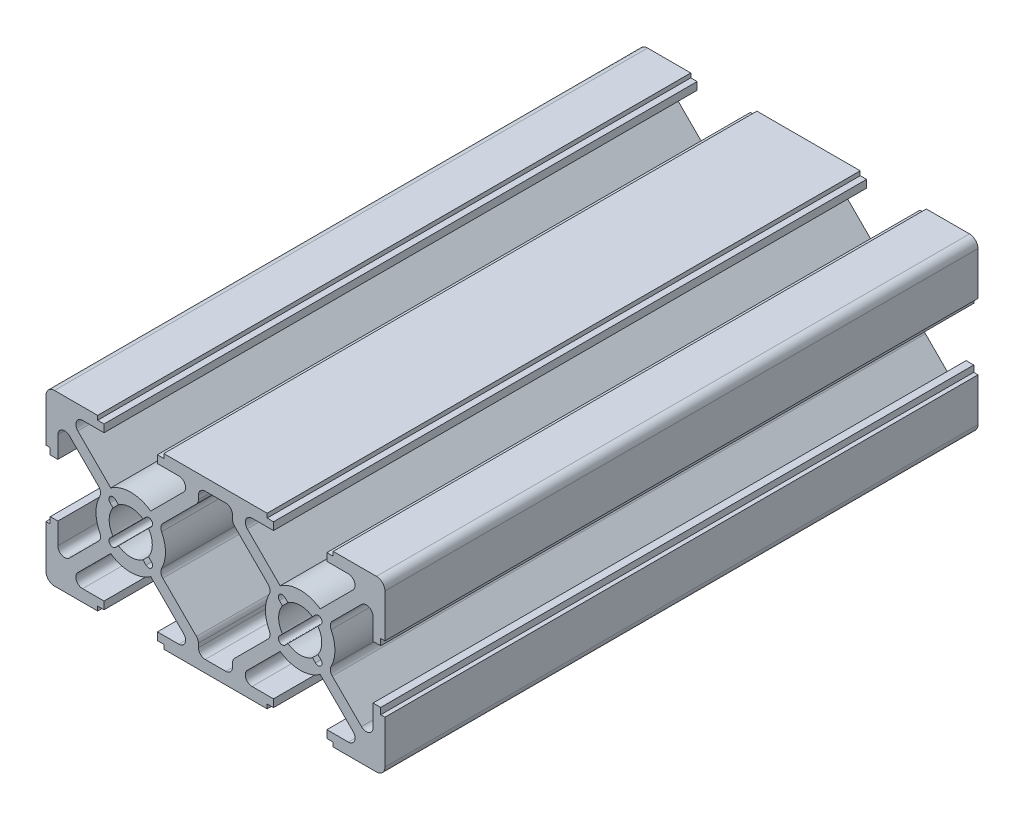
from build123d import *

# Parameters (mm, degrees)
Y_KSEKLIK_EKSTR_ZYON2_DEPTH = 70
RADYUS1_R                   = 0.8


with BuildPart() as part:
    # Çizim3 → Yükseklik-Ekstrüzyon2 (new body)
    with BuildSketch(Plane.XY):
        with BuildLine():
            Line((1, 0), (6.1, 0))
            Line((6.1, 0), (6.1, 0.5))
            Line((6.1, 0.5), (6.85, 0.5))
            Line((6.85, 0.5), (6.85, 1.4))
            Line((6.85, 1.4), (4.321320344, 1.4))
            ThreePointArc((4.321320344, 1.4), (3.582216718, 1.893853254), (3.755634919, 2.765685425))
            Line((3.755634919, 2.765685425), (7.638403375, 6.648453882))
            ThreePointArc((7.638403375, 6.648453882), (10, 5.9), (12.361596625, 6.648453882))
            Line((12.361596625, 6.648453882), (16.244365081, 2.765685425))
            ThreePointArc((16.244365081, 2.765685425), (16.417783282, 1.893853254), (15.678679656, 1.4))
            Line((15.678679656, 1.4), (13.15, 1.4))
            Line((13.15, 1.4), (13.15, 0.5))
            Line((13.15, 0.5), (13.9, 0.5))
            Line((13.9, 0.5), (13.9, 0))
            Line((13.9, 0), (26.1, 0))
            Line((26.1, 0), (26.1, 0.5))
            Line((26.1, 0.5), (26.85, 0.5))
            Line((26.85, 0.5), (26.85, 1.4))
            Line((26.85, 1.4), (24.321320344, 1.4))
            ThreePointArc((24.321320344, 1.4), (23.582216718, 1.893853254), (23.755634919, 2.765685425))
            Line((23.755634919, 2.765685425), (27.638403375, 6.648453882))
            ThreePointArc((27.638403375, 6.648453882), (30, 5.9), (32.361596625, 6.648453882))
            Line((32.361596625, 6.648453882), (36.244365081, 2.765685425))
            ThreePointArc((36.244365081, 2.765685425), (36.417783282, 1.893853254), (35.678679656, 1.4))
            Line((35.678679656, 1.4), (33.15, 1.4))
            Line((33.15, 1.4), (33.15, 0.5))
            Line((33.15, 0.5), (33.9, 0.5))
            Line((33.9, 0.5), (33.9, 0))
            Line((33.9, 0), (39, 0))
            ThreePointArc((39, 0), (39.707106781, 0.292893219), (40, 1))
            Line((40, 1), (40, 6.1))
            Line((40, 6.1), (39.5, 6.1))
            Line((39.5, 6.1), (39.5, 6.85))
            Line((39.5, 6.85), (38.6, 6.85))
            Line((38.6, 6.85), (38.6, 4.321320344))
            ThreePointArc((38.6, 4.321320344), (38.106146746, 3.582216718), (37.234314575, 3.755634919))
            Line((37.234314575, 3.755634919), (33.351546118, 7.638403375))
            ThreePointArc((33.351546118, 7.638403375), (34.1, 10), (33.351546118, 12.361596625))
            Line((33.351546118, 12.361596625), (37.234314575, 16.244365081))
            ThreePointArc((37.234314575, 16.244365081), (38.106146746, 16.417783282), (38.6, 15.678679656))
            Line((38.6, 15.678679656), (38.6, 13.15))
            Line((38.6, 13.15), (39.5, 13.15))
            Line((39.5, 13.15), (39.5, 13.9))
            Line((39.5, 13.9), (40, 13.9))
            Line((40, 13.9), (40, 19))
            ThreePointArc((40, 19), (39.707106781, 19.707106781), (39, 20))
            Line((39, 20), (33.9, 20))
            Line((33.9, 20), (33.9, 19.5))
            Line((33.9, 19.5), (33.15, 19.5))
            Line((33.15, 19.5), (33.15, 18.6))
            Line((33.15, 18.6), (35.678679656, 18.6))
            ThreePointArc((35.678679656, 18.6), (36.417783282, 18.106146746), (36.244365081, 17.234314575))
            Line((36.244365081, 17.234314575), (32.361596625, 13.351546118))
            ThreePointArc((32.361596625, 13.351546118), (30, 14.1), (27.638403375, 13.351546118))
            Line((27.638403375, 13.351546118), (23.755634919, 17.234314575))
            ThreePointArc((23.755634919, 17.234314575), (23.582216718, 18.106146746), (24.321320344, 18.6))
            Line((24.321320344, 18.6), (26.85, 18.6))
            Line((26.85, 18.6), (26.85, 19.5))
            Line((26.85, 19.5), (26.1, 19.5))
            Line((26.1, 19.5), (26.1, 20))
            Line((26.1, 20), (13.9, 20))
            Line((13.9, 20), (13.9, 19.5))
            Line((13.9, 19.5), (13.15, 19.5))
            Line((13.15, 19.5), (13.15, 18.6))
            Line((13.15, 18.6), (15.678679656, 18.6))
            ThreePointArc((15.678679656, 18.6), (16.417783282, 18.106146746), (16.244365081, 17.234314575))
            Line((16.244365081, 17.234314575), (12.361596625, 13.351546118))
            ThreePointArc((12.361596625, 13.351546118), (10, 14.1), (7.638403375, 13.351546118))
            Line((7.638403375, 13.351546118), (3.755634919, 17.234314575))
            ThreePointArc((3.755634919, 17.234314575), (3.582216718, 18.106146746), (4.321320344, 18.6))
            Line((4.321320344, 18.6), (6.85, 18.6))
            Line((6.85, 18.6), (6.85, 19.5))
            Line((6.85, 19.5), (6.1, 19.5))
            Line((6.1, 19.5), (6.1, 20))
            Line((6.1, 20), (1, 20))
            ThreePointArc((1, 20), (0.292893219, 19.707106781), (0, 19))
            Line((0, 19), (0, 13.9))
            Line((0, 13.9), (0.5, 13.9))
            Line((0.5, 13.9), (0.5, 13.15))
            Line((0.5, 13.15), (1.4, 13.15))
            Line((1.4, 13.15), (1.4, 15.678679656))
            ThreePointArc((1.4, 15.678679656), (1.893853254, 16.417783282), (2.765685425, 16.244365081))
            Line((2.765685425, 16.244365081), (6.648453882, 12.361596625))
            ThreePointArc((6.648453882, 12.361596625), (5.9, 10), (6.648453882, 7.638403375))
            Line((6.648453882, 7.638403375), (2.765685425, 3.755634919))
            ThreePointArc((2.765685425, 3.755634919), (1.893853254, 3.582216718), (1.4, 4.321320344))
            Line((1.4, 4.321320344), (1.4, 6.85))
            Line((1.4, 6.85), (0.5, 6.85))
            Line((0.5, 6.85), (0.5, 6.1))
            Line((0.5, 6.1), (0, 6.1))
            Line((0, 6.1), (0, 1))
            ThreePointArc((0, 1), (0.292893219, 0.292893219), (1, 0))
        make_face()
        with BuildLine():
            Line((21.210320913, 18.6), (18.789679087, 18.6))
            ThreePointArc((18.789679087, 18.6), (18.223993662, 18.365685425), (17.989679087, 17.8))
            Line((17.989679087, 17.8), (17.989679087, 17.331100443))
            ThreePointArc((17.989679087, 17.331100443), (17.928782713, 17.024953697), (17.755364512, 16.765415018))
            Line((17.755364512, 16.765415018), (13.351546118, 12.361596625))
            ThreePointArc((13.351546118, 12.361596625), (14.1, 10), (13.351546118, 7.638403375))
            Line((13.351546118, 7.638403375), (17.755364512, 3.234584982))
            ThreePointArc((17.755364512, 3.234584982), (17.928782713, 2.975046303), (17.989679087, 2.668899557))
            Line((17.989679087, 2.668899557), (17.989679087, 2.2))
            ThreePointArc((17.989679087, 2.2), (18.223993662, 1.634314575), (18.789679087, 1.4))
            Line((18.789679087, 1.4), (21.210320913, 1.4))
            ThreePointArc((21.210320913, 1.4), (21.776006338, 1.634314575), (22.010320913, 2.2))
            Line((22.010320913, 2.2), (22.010320913, 2.668899557))
            ThreePointArc((22.010320913, 2.668899557), (22.071217287, 2.975046303), (22.244635488, 3.234584982))
            Line((22.244635488, 3.234584982), (26.648453882, 7.638403375))
            ThreePointArc((26.648453882, 7.638403375), (25.9, 10), (26.648453882, 12.361596625))
            Line((26.648453882, 12.361596625), (22.244635488, 16.765415018))
            ThreePointArc((22.244635488, 16.765415018), (22.071217287, 17.024953697), (22.010320913, 17.331100443))
            Line((22.010320913, 17.331100443), (22.010320913, 17.8))
            ThreePointArc((22.010320913, 17.8), (21.776006338, 18.365685425), (21.210320913, 18.6))
        make_face(mode=Mode.SUBTRACT)
        with BuildLine():
            Line((8.201142588, 12.443783276), (8.552743846, 12.092182018))
            ThreePointArc((8.552743846, 12.092182018), (10, 12.543968548), (11.447256154, 12.092182018))
            Line((11.447256154, 12.092182018), (11.798857412, 12.443783276))
            ThreePointArc((11.798857412, 12.443783276), (12.443783276, 12.443783276), (12.443783276, 11.798857412))
            Line((12.443783276, 11.798857412), (12.092182018, 11.447256154))
            ThreePointArc((12.092182018, 11.447256154), (12.543968548, 10), (12.092182018, 8.552743846))
            Line((12.092182018, 8.552743846), (12.443783276, 8.201142588))
            ThreePointArc((12.443783276, 8.201142588), (12.443783276, 7.556216724), (11.798857412, 7.556216724))
            Line((11.798857412, 7.556216724), (11.447256154, 7.907817982))
            ThreePointArc((11.447256154, 7.907817982), (10, 7.456031452), (8.552743846, 7.907817982))
            Line((8.552743846, 7.907817982), (8.201142588, 7.556216724))
            ThreePointArc((8.201142588, 7.556216724), (7.556216724, 7.556216724), (7.556216724, 8.201142588))
            Line((7.556216724, 8.201142588), (7.907817982, 8.552743846))
            ThreePointArc((7.907817982, 8.552743846), (7.456031452, 10), (7.907817982, 11.447256154))
            Line((7.907817982, 11.447256154), (7.556216724, 11.798857412))
            ThreePointArc((7.556216724, 11.798857412), (7.556216724, 12.443783276), (8.201142588, 12.443783276))
        make_face(mode=Mode.SUBTRACT)
        with BuildLine():
            Line((27.907817982, 11.447256154), (27.556216724, 11.798857412))
            ThreePointArc((27.556216724, 11.798857412), (27.556216724, 12.443783276), (28.201142588, 12.443783276))
            Line((28.201142588, 12.443783276), (28.552743846, 12.092182018))
            ThreePointArc((28.552743846, 12.092182018), (30, 12.543968548), (31.447256154, 12.092182018))
            Line((31.447256154, 12.092182018), (31.798857412, 12.443783276))
            ThreePointArc((31.798857412, 12.443783276), (32.443783276, 12.443783276), (32.443783276, 11.798857412))
            Line((32.443783276, 11.798857412), (32.092182018, 11.447256154))
            ThreePointArc((32.092182018, 11.447256154), (32.543968548, 10), (32.092182018, 8.552743846))
            Line((32.092182018, 8.552743846), (32.443783276, 8.201142588))
            ThreePointArc((32.443783276, 8.201142588), (32.443783276, 7.556216724), (31.798857412, 7.556216724))
            Line((31.798857412, 7.556216724), (31.447256154, 7.907817982))
            ThreePointArc((31.447256154, 7.907817982), (30, 7.456031452), (28.552743846, 7.907817982))
            Line((28.552743846, 7.907817982), (28.201142588, 7.556216724))
            ThreePointArc((28.201142588, 7.556216724), (27.556216724, 7.556216724), (27.556216724, 8.201142588))
            Line((27.556216724, 8.201142588), (27.907817982, 8.552743846))
            ThreePointArc((27.907817982, 8.552743846), (27.456031452, 10), (27.907817982, 11.447256154))
        make_face(mode=Mode.SUBTRACT)
    extrude(amount=Y_KSEKLIK_EKSTR_ZYON2_DEPTH)

    # Radyus1
    radyus1_edges = [part.edges().sort_by_distance(p)[0] for p in [
        (6.648453882, 7.638403375, 35),
        (6.648453882, 12.361596625, 35),
        (33.351546118, 12.361596625, 35),
        (33.351546118, 7.638403375, 35),
        (13.351546118, 12.361596625, 35),
        (13.351546118, 7.638403375, 35),
        (26.648453882, 7.638403375, 35),
        (26.648453882, 12.361596625, 35),
    ]]
    fillet(radyus1_edges, radius=RADYUS1_R)


solid = part.part
